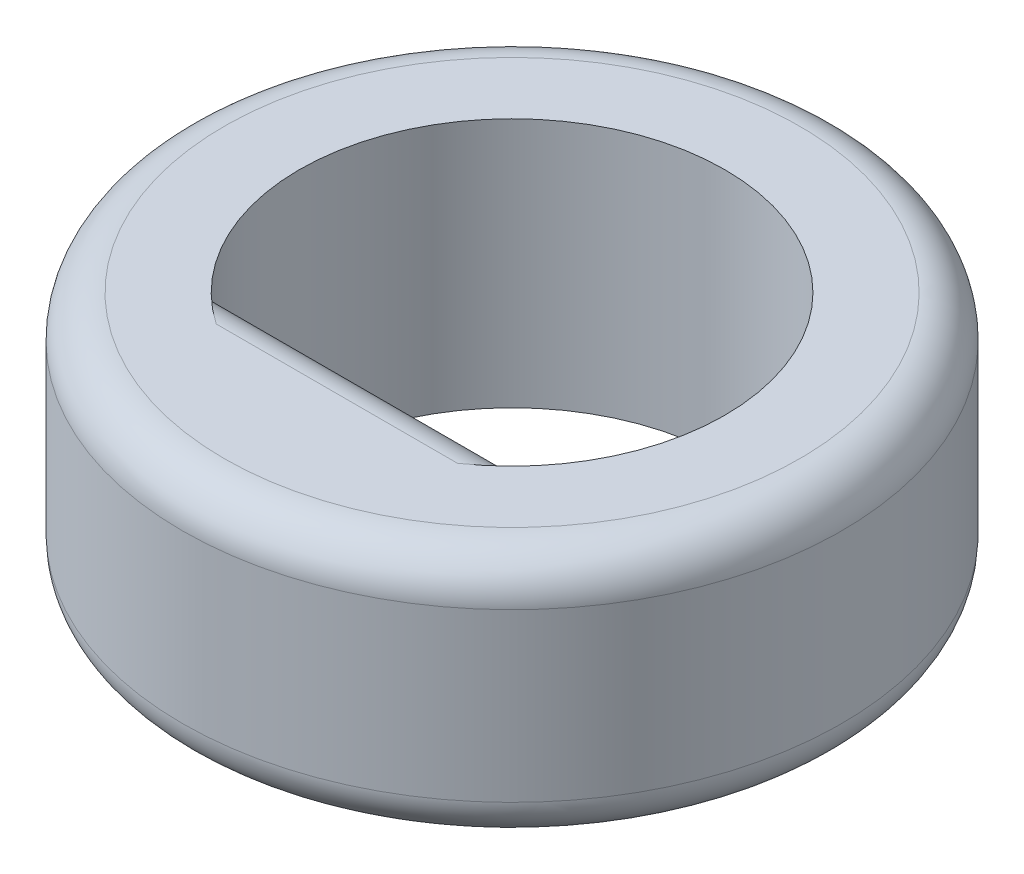
from build123d import *

# Parameters (mm, degrees)
SKETCH1_R           = 3.95
BOSS_EXTRUDE1_DEPTH = 3
FILLET1_R           = 0.5


with BuildPart() as part:
    # Sketch1 → Boss-Extrude1 (new body)
    with BuildSketch(Plane(origin=(0, 0, 0), x_dir=(1, 0, 0), z_dir=(0, 1, 0))):
        Circle(SKETCH1_R)
        with BuildLine():
            Line((-1.985572965, -1.6), (1.985572965, -1.6))
            ThreePointArc((1.985572965, -1.6), (0, 2.55), (-1.985572965, -1.6))
        make_face(mode=Mode.SUBTRACT)
    extrude(amount=BOSS_EXTRUDE1_DEPTH)

    # Fillet1
    fillet1_edges = [part.edges().sort_by_distance(p)[0] for p in [
        (-3.95, 0, 0),
        (-3.95, 3, 0),
        (0, 0, 1.6),
        (0, 3, 1.6),
    ]]
    fillet(fillet1_edges, radius=FILLET1_R)


solid = part.part
